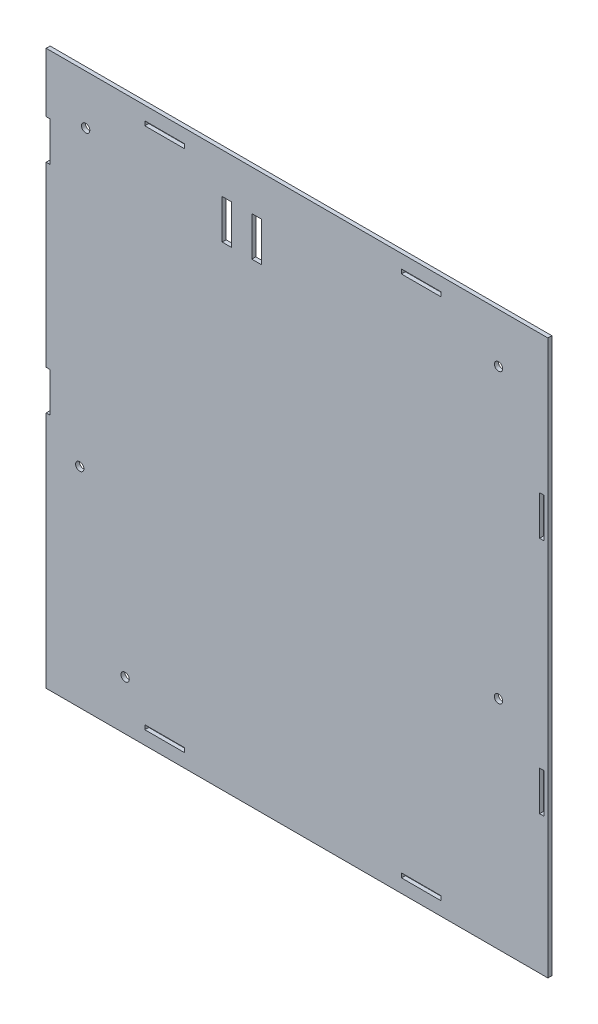
from build123d import *

# Parameters (mm, degrees)
SKETCH1_W           = 254.2
SKETCH1_H           = 280.866666666
SKETCH1_W_2         = 20
SKETCH1_H_2         = 2.2
SKETCH1_W_3         = 2.2
SKETCH1_H_3         = 20
BOSS_EXTRUDE1_DEPTH = 2
SKETCH2_W           = 4.8
SKETCH2_H           = 20
CUT_EXTRUDE1_DEPTH  = 5
SKETCH3_R           = 2.1
CUT_EXTRUDE2_DEPTH  = 5
SKETCH4_R           = 2.1
CUT_EXTRUDE3_DEPTH  = 5
SKETCH5_R           = 2.1
CUT_EXTRUDE4_DEPTH  = 5
SKETCH6_R           = 2.1
CUT_EXTRUDE5_DEPTH  = 5
SKETCH7_W           = 2
SKETCH7_H           = 20
CUT_EXTRUDE6_DEPTH  = 10


with BuildPart() as part:
    # Sketch1 → Boss-Extrude1 (new body)
    with BuildSketch(Plane.XY):
        with Locations((-122.9, 135)):
            Rectangle(SKETCH1_W, SKETCH1_H)
        with Locations((-60, 267.5)):
            Rectangle(SKETCH1_W_2, SKETCH1_H_2, mode=Mode.SUBTRACT)
        with Locations((1.1, 74.566666667)):
            Rectangle(SKETCH1_W_3, SKETCH1_H_3, mode=Mode.SUBTRACT)
        with Locations((-190, 2.5)):
            Rectangle(SKETCH1_W_2, SKETCH1_H_2, mode=Mode.SUBTRACT)
        with Locations((1.1, 195.433333333)):
            Rectangle(SKETCH1_W_3, SKETCH1_H_3, mode=Mode.SUBTRACT)
        with Locations((-60, 2.5)):
            Rectangle(SKETCH1_W_2, SKETCH1_H_2, mode=Mode.SUBTRACT)
        with Locations((-190, 267.5)):
            Rectangle(SKETCH1_W_2, SKETCH1_H_2, mode=Mode.SUBTRACT)
    extrude(amount=BOSS_EXTRUDE1_DEPTH)

    # Sketch2 → Cut-Extrude1 (cut)
    with BuildSketch(Plane.XY.offset(2)):
        with Locations((-143.405234687, 245)):
            Rectangle(SKETCH2_W, SKETCH2_H)
        with Locations((-158.405234687, 245)):
            Rectangle(SKETCH2_W, SKETCH2_H)
    extrude(amount=-CUT_EXTRUDE1_DEPTH, mode=Mode.SUBTRACT)

    # Sketch3 → Cut-Extrude2 (cut)
    with BuildSketch(Plane.XY.offset(2)):
        with Locations((-230, 250.433333333)):
            Circle(SKETCH3_R)
        with Locations((-20.8, 250.433333333)):
            Circle(SKETCH3_R)
    extrude(amount=-CUT_EXTRUDE2_DEPTH, mode=Mode.SUBTRACT)

    # Sketch4 → Cut-Extrude3 (cut)
    with BuildSketch(Plane.XY.offset(2)):
        with Locations((-210, 19.566666667)):
            Circle(SKETCH4_R)
    extrude(amount=-CUT_EXTRUDE3_DEPTH, mode=Mode.SUBTRACT)

    # Sketch5 → Cut-Extrude4 (cut)
    with BuildSketch(Plane.XY.offset(2)):
        with Locations((-20.8, 104.566666667)):
            Circle(SKETCH5_R)
    extrude(amount=-CUT_EXTRUDE4_DEPTH, mode=Mode.SUBTRACT)

    # Sketch6 → Cut-Extrude5 (cut)
    with BuildSketch(Plane.XY.offset(2)):
        with Locations((-233, 100.433333333)):
            Circle(SKETCH6_R)
    extrude(amount=-CUT_EXTRUDE5_DEPTH, mode=Mode.SUBTRACT)

    # Sketch7 → Cut-Extrude6 (cut)
    with BuildSketch(Plane.XY.offset(2)):
        with Locations((-249, 235.433333333)):
            Rectangle(SKETCH7_W, SKETCH7_H)
        with Locations((-249, 125.433333333)):
            Rectangle(SKETCH7_W, SKETCH7_H)
    extrude(amount=-CUT_EXTRUDE6_DEPTH, mode=Mode.SUBTRACT)


solid = part.part
